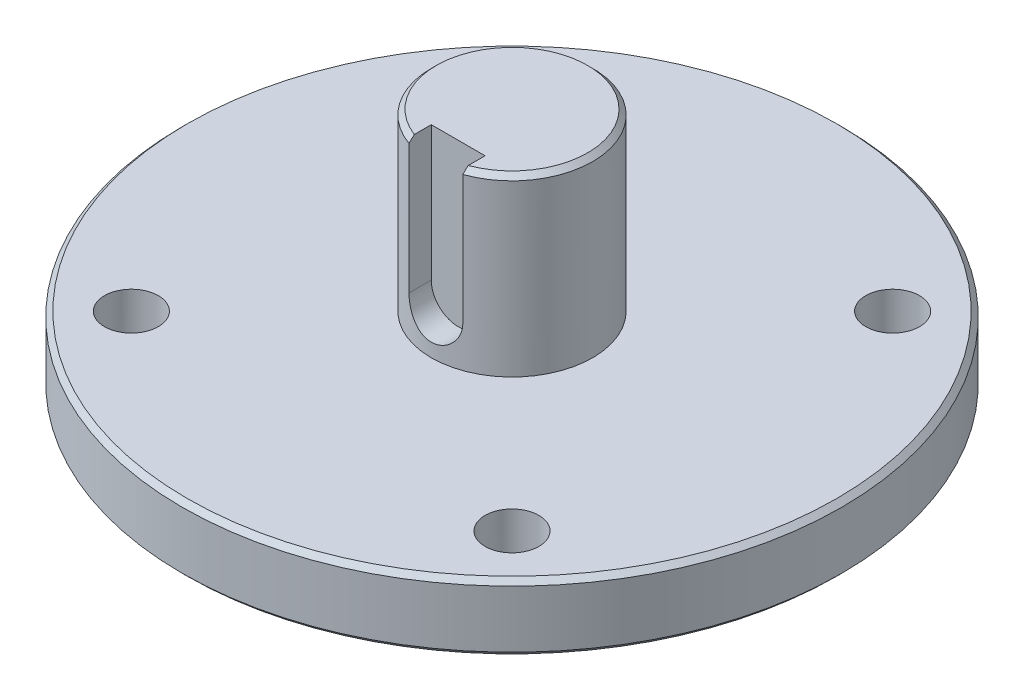
from build123d import *

# Parameters (mm, degrees)
CUT_EXTRUDE1_REACH = 76.014
SKETCH2_R          = 4
CUT_EXTRUDE2_DEPTH = 4
CHAMFER1_SIZE      = 0.75


with BuildPart() as part:
    # Sketch1 → Revolve1 (revolve)
    with BuildSketch(Plane.XY):
        Polygon((0, 0), (-49, 0), (-49, 10), (-12, 10), (-12, 36), (0, 36), align=None)
    revolve(axis=Axis((0, 36, 0), (0, -1, 0)))

    # Sketch2 → Cut-Extrude1 (cut, up to next)
    with BuildSketch(Plane(origin=(0, 10, 0), x_dir=(1, 0, 0), z_dir=(0, 1, 0)), mode=Mode.PRIVATE) as cut_extrude1_sk1:
        with Locations((-28.284271247, 28.284271247)):
            Circle(SKETCH2_R)
    cut_extrude1_tool1 = extrude(cut_extrude1_sk1.sketch, amount=-CUT_EXTRUDE1_REACH, mode=Mode.PRIVATE) & part.part
    # Sketch2 → Cut-Extrude1 (cut, up to next)
    with BuildSketch(Plane(origin=(0, 10, 0), x_dir=(1, 0, 0), z_dir=(0, 1, 0)), mode=Mode.PRIVATE) as cut_extrude1_sk2:
        with Locations((28.284271247, 28.284271247)):
            Circle(SKETCH2_R)
    cut_extrude1_tool2 = extrude(cut_extrude1_sk2.sketch, amount=-CUT_EXTRUDE1_REACH, mode=Mode.PRIVATE) & part.part
    # Sketch2 → Cut-Extrude1 (cut, up to next)
    with BuildSketch(Plane(origin=(0, 10, 0), x_dir=(1, 0, 0), z_dir=(0, 1, 0)), mode=Mode.PRIVATE) as cut_extrude1_sk3:
        with Locations((28.284271247, -28.284271247)):
            Circle(SKETCH2_R)
    cut_extrude1_tool3 = extrude(cut_extrude1_sk3.sketch, amount=-CUT_EXTRUDE1_REACH, mode=Mode.PRIVATE) & part.part
    # Sketch2 → Cut-Extrude1 (cut, up to next)
    with BuildSketch(Plane(origin=(0, 10, 0), x_dir=(1, 0, 0), z_dir=(0, 1, 0)), mode=Mode.PRIVATE) as cut_extrude1_sk4:
        with Locations((-28.284271247, -28.284271247)):
            Circle(SKETCH2_R)
    cut_extrude1_tool4 = extrude(cut_extrude1_sk4.sketch, amount=-CUT_EXTRUDE1_REACH, mode=Mode.PRIVATE) & part.part
    add(cut_extrude1_tool1.solids().sort_by_distance((-28.284271, 10, -28.284271))[0], mode=Mode.SUBTRACT)
    add(cut_extrude1_tool2.solids().sort_by_distance((28.284271, 10, -28.284271))[0], mode=Mode.SUBTRACT)
    add(cut_extrude1_tool3.solids().sort_by_distance((28.284271, 10, 28.284271))[0], mode=Mode.SUBTRACT)
    add(cut_extrude1_tool4.solids().sort_by_distance((-28.284271, 10, 28.284271))[0], mode=Mode.SUBTRACT)

    # Sketch3 → Cut-Extrude2 (cut)
    with BuildSketch(Plane.XY.offset(12)):
        with BuildLine():
            Line((-4, 36), (4, 36))
            Line((4, 36), (4, 16))
            ThreePointArc((4, 16), (0, 12), (-4, 16))
            Line((-4, 16), (-4, 36))
        make_face()
    extrude(amount=-CUT_EXTRUDE2_DEPTH, mode=Mode.SUBTRACT)

    # Chamfer1
    chamfer1_edges = [part.edges().sort_by_distance(p)[0] for p in [
        (49, 0, 0),
        (49, 10, 0),
        (6.92820323, 36, -9.797958971),
    ]]
    chamfer(chamfer1_edges, length=CHAMFER1_SIZE)


solid = part.part
